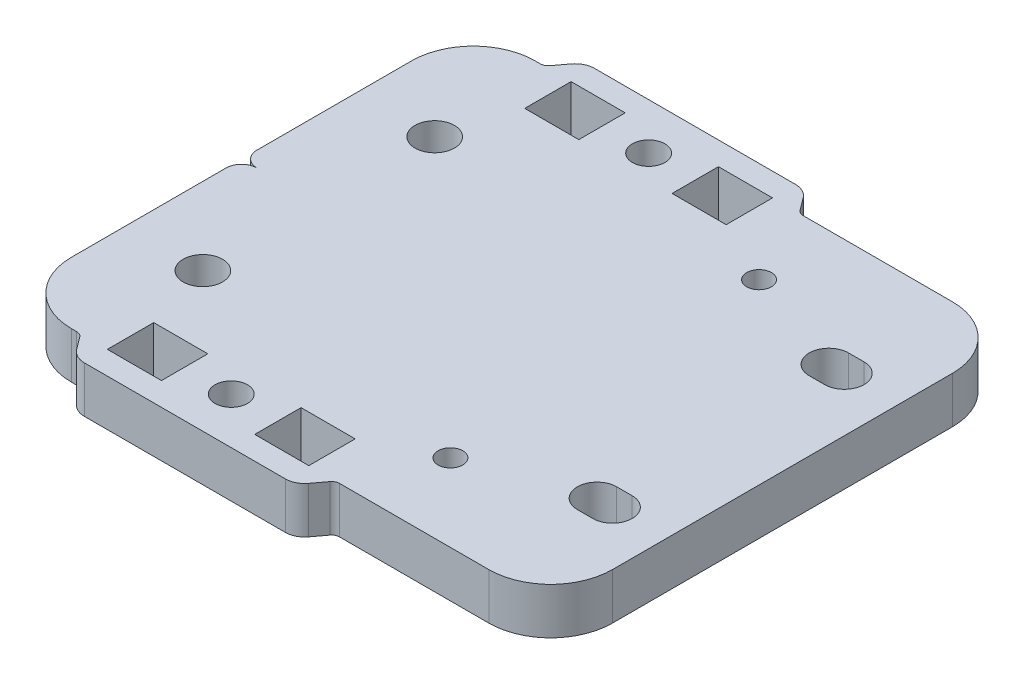
from build123d import *

# Parameters (mm, degrees)
EXTRUDE_1_DEPTH      = 6
SKETCH_2_R           = 2.55
SKETCH_2_R_2         = 1.6
CUT_EXTRUDE_1_DEPTH  = 7
CUT_EXTRUDE_2_DEPTH  = 7
EXTRUDE_2_DEPTH      = 6
SKETCH_31_R          = 2.1
SKETCH_31_W          = 7
SKETCH_31_H          = 6
CUT_EXTRUDE_11_DEPTH = 7
EXTRUDE_21_DEPTH     = 6
SKETCH_33_R          = 2.1
SKETCH_33_W          = 7
SKETCH_33_H          = 6
CUT_EXTRUDE_13_DEPTH = 7


with BuildPart() as part:
    # Эскиз1 → Бобышка-Вытянуть1 (new body)
    with BuildSketch(Plane(origin=(0, 0, 0), x_dir=(1, 0, 0), z_dir=(0, 1, 0))):
        with BuildLine():
            Line((-27, -30), (27, -30))
            ThreePointArc((27, -30), (32.656854249, -27.656854249), (35, -22))
            Line((35, -22), (35, 22))
            ThreePointArc((35, 22), (32.656854249, 27.656854249), (27, 30))
            Line((27, 30), (-27, 30))
            ThreePointArc((-27, 30), (-32.656854249, 27.656854249), (-35, 22))
            Line((-35, 22), (-35, -22))
            ThreePointArc((-35, -22), (-32.656854249, -27.656854249), (-27, -30))
        make_face()
    extrude(amount=EXTRUDE_1_DEPTH)

    # Эскиз2 → Вырез-Вытянуть1 (cut, through all)
    with BuildSketch(Plane.XZ):
        with Locations((-25, -15)):
            Circle(SKETCH_2_R)
        with Locations((-25, 15)):
            Circle(SKETCH_2_R)
        with Locations((12, 19.966651117)):
            Circle(SKETCH_2_R_2)
        with Locations((12, -19.966651117)):
            Circle(SKETCH_2_R_2)
        with BuildLine():
            Line((28, -17.55), (26, -17.55))
            ThreePointArc((26, -17.55), (23.45, -15), (26, -12.45))
            Line((26, -12.45), (28, -12.45))
            ThreePointArc((28, -12.45), (30.55, -15), (28, -17.55))
        make_face()
        with BuildLine():
            Line((28, 17.55), (26, 17.55))
            ThreePointArc((26, 17.55), (23.45, 15), (26, 12.45))
            Line((26, 12.45), (28, 12.45))
            ThreePointArc((28, 12.45), (30.55, 15), (28, 17.55))
        make_face()
    extrude(amount=-CUT_EXTRUDE_1_DEPTH, mode=Mode.SUBTRACT)

    # Эскиз3 → Вырез-Вытянуть2 (cut, through all)
    with BuildSketch(Plane.XZ):
        with BuildLine():
            Line((-35, -2), (-35, 2))
            ThreePointArc((-35, 2), (-34.414213562, 0.585786438), (-33, 0))
            ThreePointArc((-33, 0), (-34.414213562, -0.585786438), (-35, -2))
        make_face()
    extrude(amount=-CUT_EXTRUDE_2_DEPTH, mode=Mode.SUBTRACT)

    # Эскиз21 → Бобышка-Вытянуть2 (add)
    with BuildSketch(Plane(origin=(-9.322772353, 6, 20), x_dir=(-1, 0, 0), z_dir=(0, -1, 0))):
        with BuildLine():
            Line((13, 53), (-13, 53))
            ThreePointArc((-13, 53), (-14.118033989, 52.736067977), (-15, 52))
            Line((-15, 52), (-16.2, 50.4))
            ThreePointArc((-16.2, 50.4), (-16.552786405, 50.105572809), (-17, 50))
            Line((-17, 50), (17, 50))
            ThreePointArc((17, 50), (16.552786405, 50.105572809), (16.2, 50.4))
            Line((16.2, 50.4), (15, 52))
            ThreePointArc((15, 52), (14.118033989, 52.736067977), (13, 53))
        make_face()
    extrude(amount=EXTRUDE_2_DEPTH)

    # Эскиз31 → Вырез-Вытянуть11 (cut, through all)
    with BuildSketch(Plane(origin=(-9.322772353, 0, 20), x_dir=(-1, 0, 0), z_dir=(0, -1, 0))):
        with Locations((0, 47)):
            Circle(SKETCH_31_R)
        with Locations((9.531849908, 47)):
            Rectangle(SKETCH_31_W, SKETCH_31_H)
        with Locations((-9.531849908, 47)):
            Rectangle(SKETCH_31_W, SKETCH_31_H)
    extrude(amount=-CUT_EXTRUDE_11_DEPTH, mode=Mode.SUBTRACT)

    # Эскиз22 → Бобышка-Вытянуть21 (add)
    with BuildSketch(Plane(origin=(-9.322772353, 6, -20), x_dir=(1, 0, 0), z_dir=(0, -1, 0))):
        with BuildLine():
            Line((13, 53), (-13, 53))
            ThreePointArc((-13, 53), (-14.118033989, 52.736067977), (-15, 52))
            Line((-15, 52), (-16.2, 50.4))
            ThreePointArc((-16.2, 50.4), (-16.552786405, 50.105572809), (-17, 50))
            Line((-17, 50), (17, 50))
            ThreePointArc((17, 50), (16.552786405, 50.105572809), (16.2, 50.4))
            Line((16.2, 50.4), (15, 52))
            ThreePointArc((15, 52), (14.118033989, 52.736067977), (13, 53))
        make_face()
    extrude(amount=EXTRUDE_21_DEPTH)

    # Эскиз33 → Вырез-Вытянуть13 (cut, through all)
    with BuildSketch(Plane(origin=(-9.322772353, 0, -20), x_dir=(1, 0, 0), z_dir=(0, -1, 0))):
        with Locations((0, 47)):
            Circle(SKETCH_33_R)
        with Locations((9.531849908, 47)):
            Rectangle(SKETCH_33_W, SKETCH_33_H)
        with Locations((-9.531849908, 47)):
            Rectangle(SKETCH_33_W, SKETCH_33_H)
    extrude(amount=-CUT_EXTRUDE_13_DEPTH, mode=Mode.SUBTRACT)


solid = part.part
